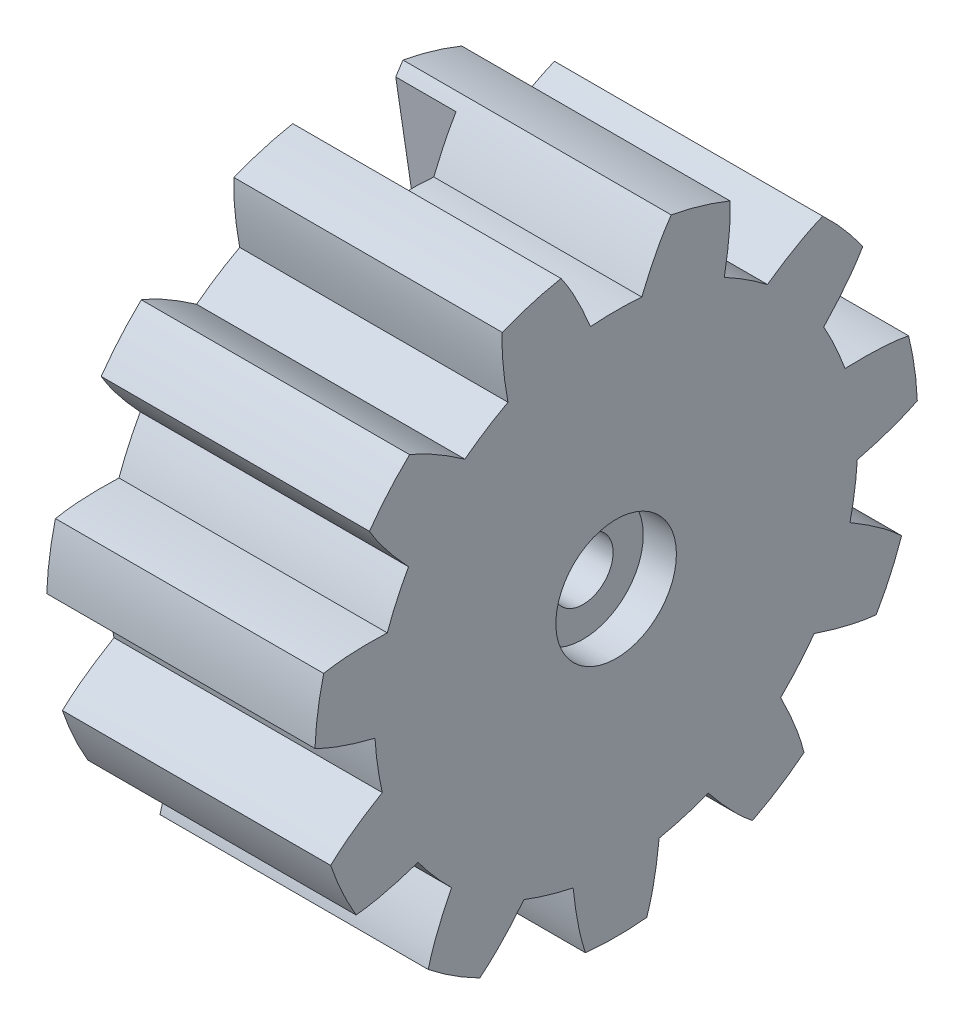
from build123d import *

# Parameters (mm, degrees)
SKETCH2_R           = 10
SKETCH2_R_2         = 1
BOSS_EXTRUDE2_DEPTH = 8.9
SKETCH6_W           = 1.518009011
SKETCH6_H           = 0.616954646
CUT_EXTRUDE4_DEPTH  = 10
CIRPATTERN2_COUNT   = 11
SKETCH9_R           = 1
CUT_EXTRUDE6_DEPTH  = 2
SKETCH7_R           = 2
SKETCH7_R_2         = 1
CUT_EXTRUDE5_DEPTH  = 1.1


with BuildPart() as part:
    # Sketch2 → Boss-Extrude2 (new body)
    with BuildSketch(Plane(origin=(0, 0, 0), x_dir=(0, 0, -1), z_dir=(1, 0, 0))):
        Circle(SKETCH2_R)
        Circle(SKETCH2_R_2, mode=Mode.SUBTRACT)
    extrude(amount=BOSS_EXTRUDE2_DEPTH)

    # Sketch6 → Cut-Extrude4 (cut)
    with BuildSketch(Plane(origin=(0, 0, 0), x_dir=(0, 0, -1), z_dir=(1, 0, 0))):
        with Locations((-0.000564754, 9.986199456)):
            Rectangle(SKETCH6_W, SKETCH6_H)
        with BuildLine():
            ThreePointArc((1.85, 9.863100717), (0, 9.999274253), (-1.85, 9.863100717))
            add(Edge.make_bspline(
                [(-0.85, 7.960375373), (-1.133345882, 8.645593633), (-1.446471715, 9.299894306), (-1.85, 9.863100717)],
                knots=[0.309355195, 0.309355195, 0.309355195, 0.309355195, 0.515063523, 0.515063523, 0.515063523, 0.515063523], degree=3))
            ThreePointArc((-0.85, 7.960375373), (0, 7.994414161), (0.85, 7.960375373))
            add(Edge.make_bspline(
                [(0.85, 7.960375373), (1.133345882, 8.645593633), (1.446471715, 9.299894306), (1.85, 9.863100717)],
                knots=[0.309355195, 0.309355195, 0.309355195, 0.309355195, 0.515063523, 0.515063523, 0.515063523, 0.515063523], degree=3))
        make_face()
    cut_extrude4 = extrude(amount=CUT_EXTRUDE4_DEPTH, mode=Mode.SUBTRACT)

    # CirPattern2: Cut-Extrude4 ×11 about axis
    cirpattern2_axis = Axis((8.9, 0, 0), (-1, 0, 0))
    for i in range(1, CIRPATTERN2_COUNT):
        add(cut_extrude4.rotate(cirpattern2_axis, i * 360 / CIRPATTERN2_COUNT), mode=Mode.SUBTRACT)

    # Sketch9 → Cut-Extrude6 (cut)
    with BuildSketch(Plane.ZY):
        with BuildLine():
            add(Edge.make_bspline(
                [(-0.85, 7.960375373), (-1.068952888, 8.489871392), (-1.305688222, 9.000905649), (-1.588178753, 9.465711111)],
                knots=[0.309355195, 0.309355195, 0.309355195, 0.309355195, 0.468314387, 0.468314387, 0.468314387, 0.468314387], degree=3))
            Line((-1.588178753, 9.465711111), (-2.660873875, 2.273708474))
            ThreePointArc((-2.660873875, 2.273708474), (0, -3.5), (2.660873875, 2.273708474))
            Line((2.660873875, 2.273708474), (1.588178753, 9.465711111))
            add(Edge.make_bspline(
                [(0.85, 7.960375373), (1.068952888, 8.489871392), (1.305688222, 9.000905649), (1.588178753, 9.465711111)],
                knots=[0.309355195, 0.309355195, 0.309355195, 0.309355195, 0.468314387, 0.468314387, 0.468314387, 0.468314387], degree=3))
            ThreePointArc((0.85, 7.960375373), (0, 7.994414161), (-0.85, 7.960375373))
        make_face()
        Circle(SKETCH9_R, mode=Mode.SUBTRACT)
    extrude(amount=-CUT_EXTRUDE6_DEPTH, mode=Mode.SUBTRACT)

    # Sketch7 → Cut-Extrude5 (cut)
    with BuildSketch(Plane(origin=(8.9, 0, 0), x_dir=(0, 0, -1), z_dir=(1, 0, 0))):
        Circle(SKETCH7_R)
        with Locations(Location((0, 0, 0), (0, 0, 180))):  # turned: the seam where the file's is
            Circle(SKETCH7_R_2, mode=Mode.SUBTRACT)
    extrude(amount=-CUT_EXTRUDE5_DEPTH, mode=Mode.SUBTRACT)


solid = part.part
